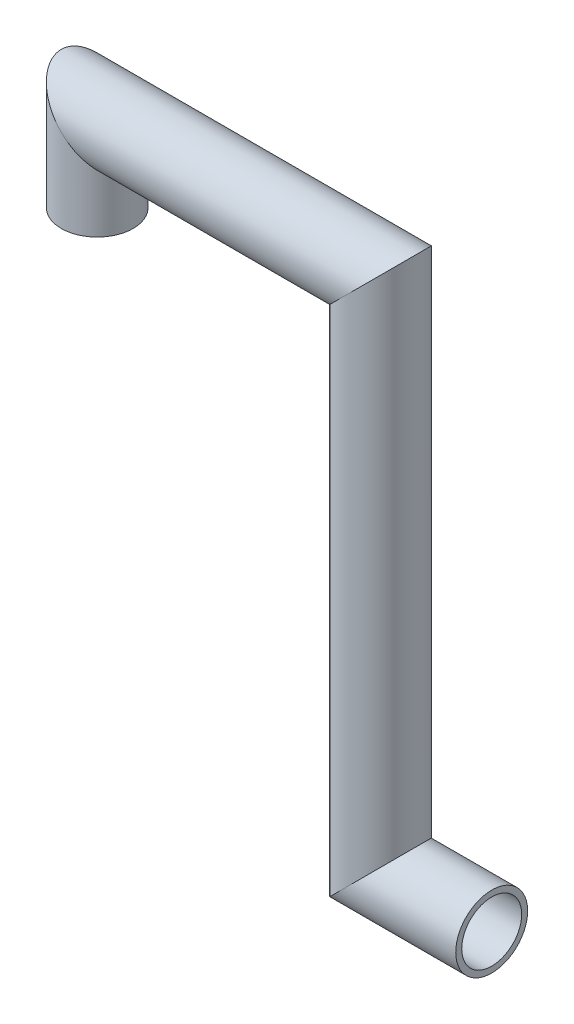
from build123d import *

# Parameters (mm, degrees)
SKETCH8_R   = 60
SKETCH8_R_2 = 50


with BuildPart() as part:
    # Sweep-Thin1: sweep along a path in Sketch1
    with BuildLine(Plane.XY) as sweep_thin1_path:
        Line((-329.073983606, 306.407118431), (-329.073983606, 445.327817433))
        Line((-329.073983606, 445.327817433), (143.609908522, 445.327817433))
        Line((143.609908522, 445.327817433), (143.609908522, -410.327817433))
        Line((143.609908522, -410.327817433), (329.073983606, -410.327817433))
    # Sketch8 → Sweep-Thin1 (sweep)
    with BuildSketch(Plane(origin=(0, 306.407118431, 0), x_dir=(1, 0, 0), z_dir=(0, 1, 0))):
        with Locations((-329.073983606, 0)):
            Circle(SKETCH8_R)
        with Locations((-329.073983606, 0)):
            Circle(SKETCH8_R_2, mode=Mode.SUBTRACT)
    sweep(path=sweep_thin1_path.line, transition=Transition.RIGHT)


solid = part.part
